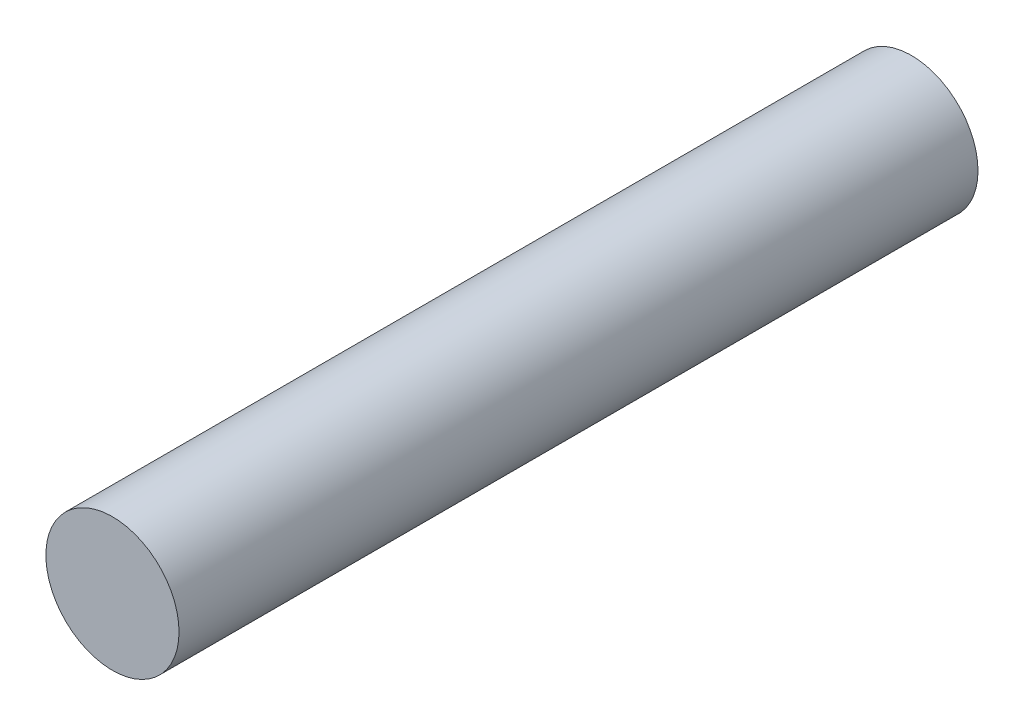
from build123d import *

# Parameters (mm, degrees)
SKETCH1_R           = 635
BOSS_EXTRUDE1_DEPTH = 3810


with BuildPart() as part:
    # Sketch1 → Boss-Extrude1 (new body, symmetric)
    with BuildSketch(Plane.XY):
        Circle(SKETCH1_R)
    extrude(amount=BOSS_EXTRUDE1_DEPTH, both=True)


solid = part.part
